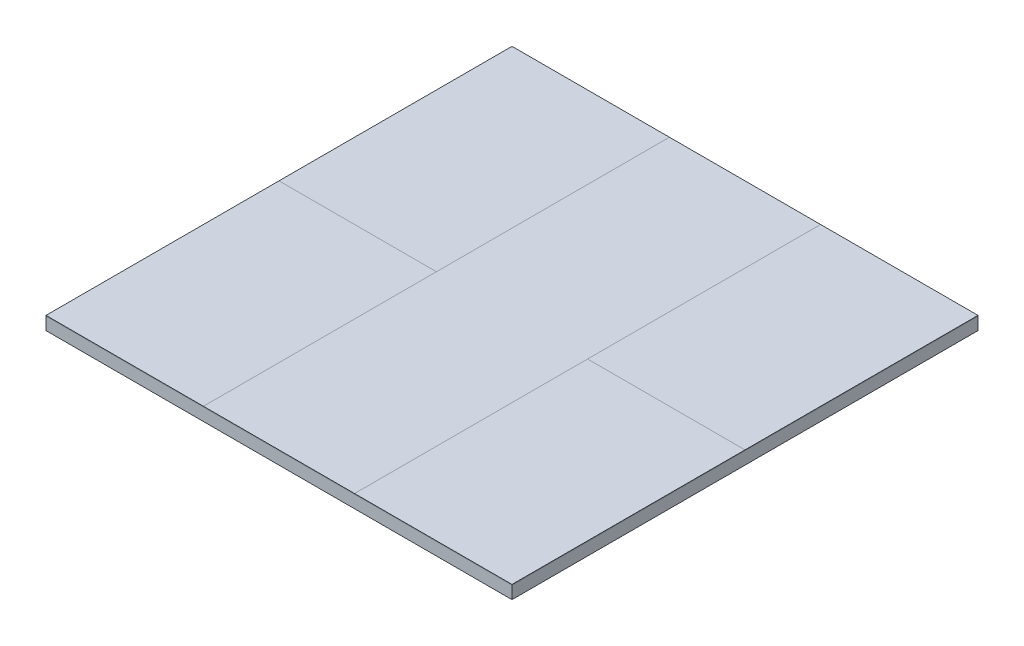
from build123d import *

# Parameters (mm, degrees)
SKETCH1_W           = 74
SKETCH1_H           = 74
BOSS_EXTRUDE1_DEPTH = 2
SKETCH2_W           = 25
SKETCH2_H           = 37
BOSS_EXTRUDE2_DEPTH = 0.1
SKETCH2_3_W         = 25
SKETCH2_3_H         = 37
BOSS_EXTRUDE3_DEPTH = 0.1
SKETCH2_4_W         = 25
SKETCH2_4_H         = 37
BOSS_EXTRUDE4_DEPTH = 0.1
BOSS_EXTRUDE5_DEPTH = 0.1
SKETCH2_6_W         = 25
SKETCH2_6_H         = 37
BOSS_EXTRUDE6_DEPTH = 0.1


with BuildPart() as part:
    # Sketch1 → Boss-Extrude1 (new body)
    with BuildSketch(Plane(origin=(0, 0, 0), x_dir=(1, 0, 0), z_dir=(0, 1, 0))):
        Rectangle(SKETCH1_W, SKETCH1_H)
    extrude(amount=BOSS_EXTRUDE1_DEPTH)


with BuildPart() as body_2:
    # Sketch2 → Boss-Extrude2 (new body)
    with BuildSketch(Plane(origin=(0, 2, 0), x_dir=(1, 0, 0), z_dir=(0, 1, 0))):
        with Locations((-24.5, 18.5)):
            Rectangle(SKETCH2_W, SKETCH2_H)
    extrude(amount=BOSS_EXTRUDE2_DEPTH)


with BuildPart() as body_3:
    # Sketch2_3 → Boss-Extrude3 (new body)
    with BuildSketch(Plane(origin=(0, 2, 0), x_dir=(1, 0, 0), z_dir=(0, 1, 0))):
        with Locations((24.5, -18.5)):
            Rectangle(SKETCH2_3_W, SKETCH2_3_H)
    extrude(amount=BOSS_EXTRUDE3_DEPTH)


with BuildPart() as body_4:
    # Sketch2_4 → Boss-Extrude4 (new body)
    with BuildSketch(Plane(origin=(0, 2, 0), x_dir=(1, 0, 0), z_dir=(0, 1, 0))):
        with Locations((-24.5, -18.5)):
            Rectangle(SKETCH2_4_W, SKETCH2_4_H)
    extrude(amount=BOSS_EXTRUDE4_DEPTH)


with BuildPart() as body_5:
    # Sketch2_5 → Boss-Extrude5 (new body)
    with BuildSketch(Plane(origin=(0, 2, 0), x_dir=(1, 0, 0), z_dir=(0, 1, 0))):
        Polygon((12, 37), (-12, 37), (-12, 0), (-12, -37), (12, -37), (12, 0), align=None)
    extrude(amount=BOSS_EXTRUDE5_DEPTH)


with BuildPart() as body_6:
    # Sketch2_6 → Boss-Extrude6 (new body)
    with BuildSketch(Plane(origin=(0, 2, 0), x_dir=(1, 0, 0), z_dir=(0, 1, 0))):
        with Locations((24.5, 18.5)):
            Rectangle(SKETCH2_6_W, SKETCH2_6_H)
    extrude(amount=BOSS_EXTRUDE6_DEPTH)


solid = Compound([part.part, body_2.part, body_3.part, body_4.part, body_5.part, body_6.part])
